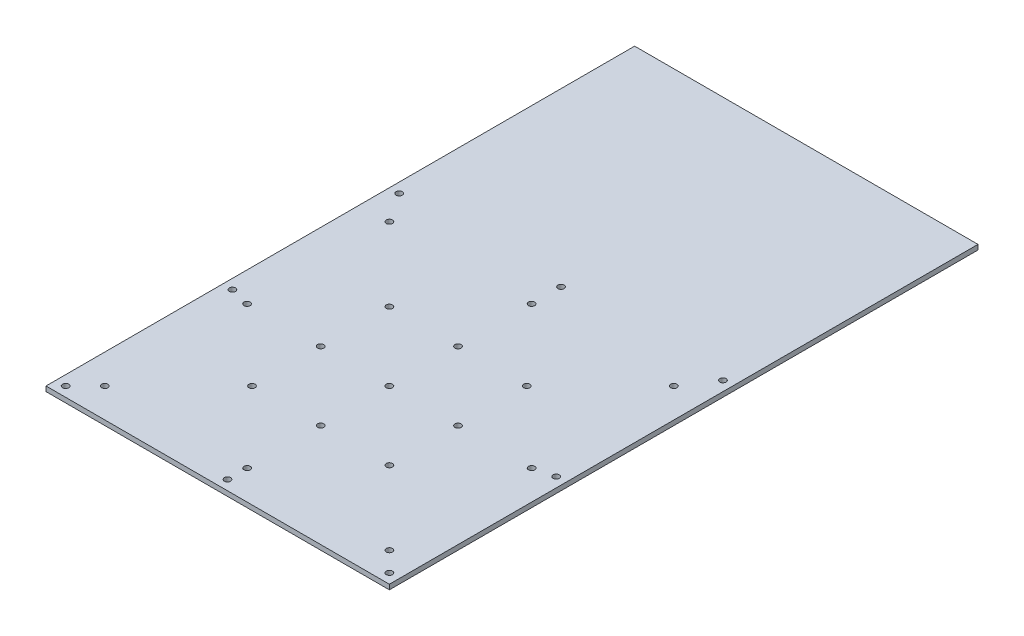
from build123d import *

# Parameters (mm, degrees)
ESQUISSE1_W        = 350
ESQUISSE1_H        = 600
ESQUISSE1_R        = 3.175
BOSS_EXTRU_1_DEPTH = 5


with BuildPart() as part:
    # Esquisse1 → Boss.-Extru.1 (new body)
    with BuildSketch(Plane(origin=(0, 0, 0), x_dir=(1, 0, 0), z_dir=(0, 1, 0))):
        with Locations((175, 300)):
            Rectangle(ESQUISSE1_W, ESQUISSE1_H)
        with Locations((10, 10)):
            Circle(ESQUISSE1_R, mode=Mode.SUBTRACT)
        with Locations((175, 10)):
            Circle(ESQUISSE1_R, mode=Mode.SUBTRACT)
        with Locations((340, 10)):
            Circle(ESQUISSE1_R, mode=Mode.SUBTRACT)
        with Locations((340, 350)):
            Circle(ESQUISSE1_R, mode=Mode.SUBTRACT)
        with Locations((340, 180)):
            Circle(ESQUISSE1_R, mode=Mode.SUBTRACT)
        with Locations((10, 180)):
            Circle(ESQUISSE1_R, mode=Mode.SUBTRACT)
        with Locations((10, 350)):
            Circle(ESQUISSE1_R, mode=Mode.SUBTRACT)
        with Locations((175, 350)):
            Circle(ESQUISSE1_R, mode=Mode.SUBTRACT)
        with Locations((320, 320)):
            Circle(ESQUISSE1_R, mode=Mode.SUBTRACT)
        with Locations((175, 320)):
            Circle(ESQUISSE1_R, mode=Mode.SUBTRACT)
        with Locations((30, 320)):
            Circle(ESQUISSE1_R, mode=Mode.SUBTRACT)
        with Locations((105, 245)):
            Circle(ESQUISSE1_R, mode=Mode.SUBTRACT)
        with Locations((175, 245)):
            Circle(ESQUISSE1_R, mode=Mode.SUBTRACT)
        with Locations((245, 245)):
            Circle(ESQUISSE1_R, mode=Mode.SUBTRACT)
        with Locations((175, 175)):
            Circle(ESQUISSE1_R, mode=Mode.SUBTRACT)
        with Locations((245, 175)):
            Circle(ESQUISSE1_R, mode=Mode.SUBTRACT)
        with Locations((320, 175)):
            Circle(ESQUISSE1_R, mode=Mode.SUBTRACT)
        with Locations((105, 175)):
            Circle(ESQUISSE1_R, mode=Mode.SUBTRACT)
        with Locations((30, 175)):
            Circle(ESQUISSE1_R, mode=Mode.SUBTRACT)
        with Locations((105, 105)):
            Circle(ESQUISSE1_R, mode=Mode.SUBTRACT)
        with Locations((175, 105)):
            Circle(ESQUISSE1_R, mode=Mode.SUBTRACT)
        with Locations((245, 105)):
            Circle(ESQUISSE1_R, mode=Mode.SUBTRACT)
        with Locations((320, 30)):
            Circle(ESQUISSE1_R, mode=Mode.SUBTRACT)
        with Locations((175, 30)):
            Circle(ESQUISSE1_R, mode=Mode.SUBTRACT)
        with Locations((30, 30)):
            Circle(ESQUISSE1_R, mode=Mode.SUBTRACT)
    extrude(amount=BOSS_EXTRU_1_DEPTH)


solid = part.part
